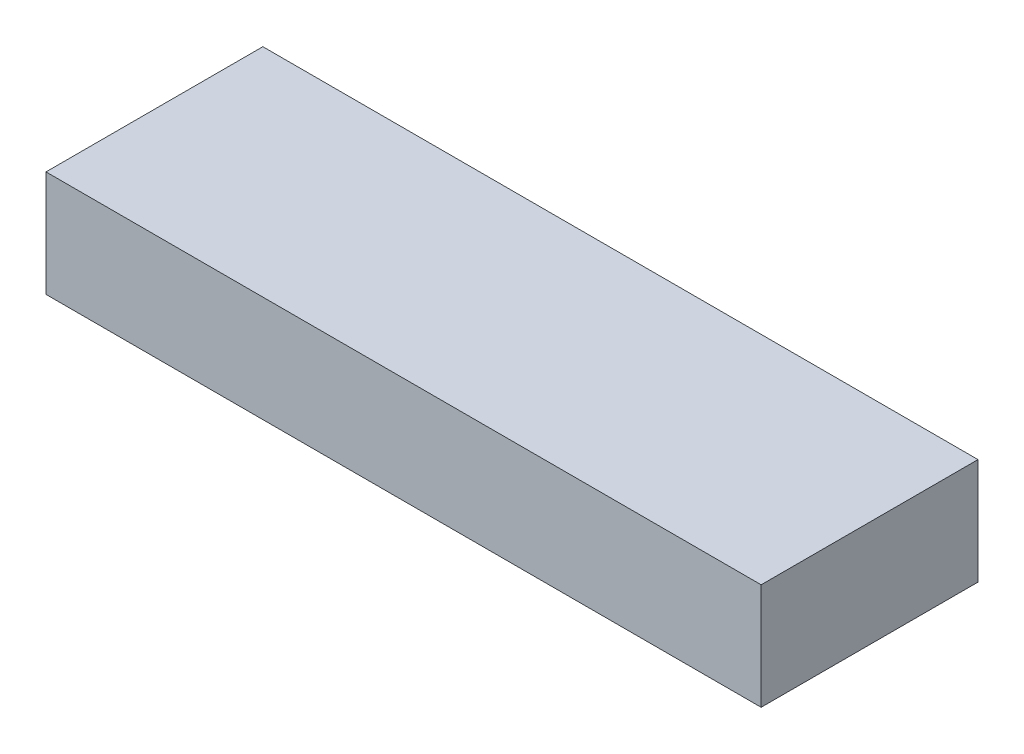
from build123d import *

# Parameters (mm, degrees)
SKETCH1_W           = 155
SKETCH1_H           = 47
BOSS_EXTRUDE1_DEPTH = 23


with BuildPart() as part:
    # Sketch1 → Boss-Extrude1 (new body)
    with BuildSketch(Plane(origin=(0, 0, 0), x_dir=(1, 0, 0), z_dir=(0, 1, 0))):
        Rectangle(SKETCH1_W, SKETCH1_H)
    extrude(amount=BOSS_EXTRUDE1_DEPTH)


solid = part.part
